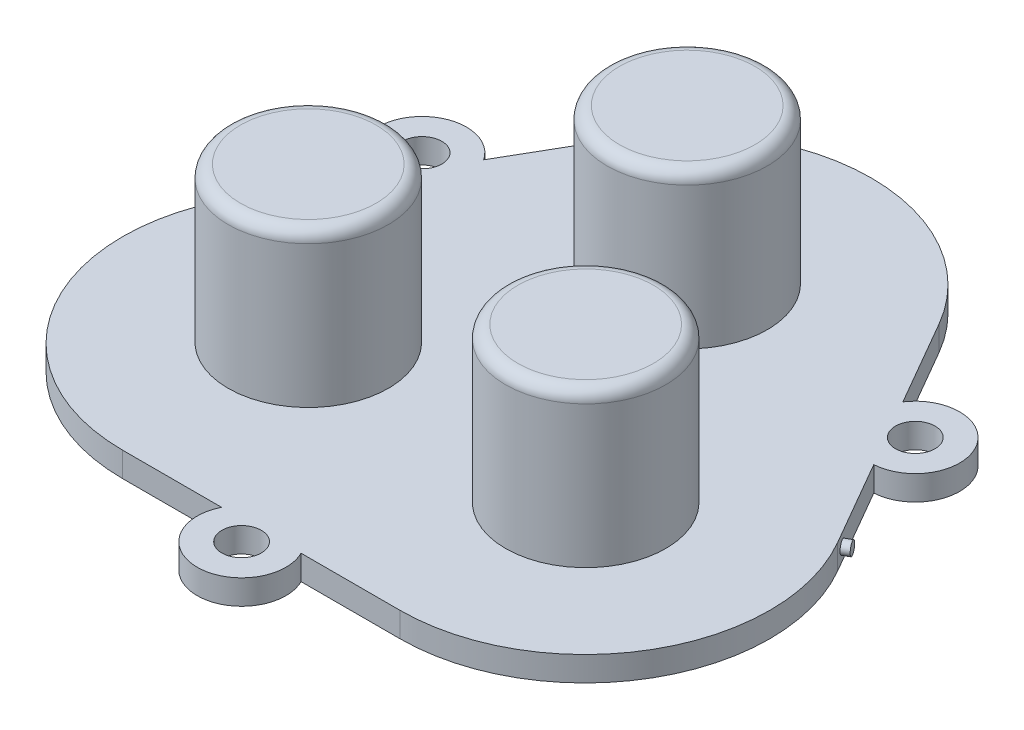
from build123d import *

# Parameters (mm, degrees)
SKETCH5_R           = 1.6
BOSS_EXTRUDE2_DEPTH = 2
SKETCH6_R           = 6.5
BOSS_EXTRUDE3_DEPTH = 14.5
FILLET1_R           = 1
SKETCH7_R           = 0.5
BOSS_EXTRUDE4_DEPTH = 0.6


with BuildPart() as part:
    # Sketch5 → Boss-Extrude2 (new body)
    with BuildSketch(Plane(origin=(0, 0, 0), x_dir=(1, 0, 0), z_dir=(0, 1, 0))):
        with BuildLine():
            Line((-11.250000051, -22.142785594), (-3.22490315, -22.142785594))
            ThreePointArc((-3.22490315, -22.142785594), (-5.1e-08, -27.342785594), (3.224903048, -22.142785594))
            Line((3.224903048, -22.142785594), (11.249999949, -22.142785594))
            ThreePointArc((11.249999949, -22.142785594), (24.240381006, -14.642785594), (24.240381006, 0.357214406))
            Line((24.240381006, 0.357214406), (20.227832555, 7.30715219))
            ThreePointArc((20.227832555, 7.30715219), (23.118713105, 12.700000199), (17.002929456, 12.892848208))
            Line((17.002929456, 12.892848208), (12.990381006, 19.842785992))
            ThreePointArc((12.990381006, 19.842785992), (-5.1e-08, 27.342785992), (-12.990381108, 19.842785992))
            Line((-12.990381108, 19.842785992), (-17.002929558, 12.892848208))
            ThreePointArc((-17.002929558, 12.892848208), (-23.118713208, 12.700000199), (-20.227832658, 7.30715219))
            Line((-20.227832658, 7.30715219), (-24.240381108, 0.357214406))
            ThreePointArc((-24.240381108, 0.357214406), (-24.240381108, -14.642785594), (-11.250000051, -22.142785594))
        make_face()
        with Locations((20.001021652, 10.900000199)):
            Circle(SKETCH5_R, mode=Mode.SUBTRACT)
        with Locations((-5.1e-08, -23.742785594)):
            Circle(SKETCH5_R, mode=Mode.SUBTRACT)
        with Locations((-20.001021754, 10.900000199)):
            Circle(SKETCH5_R, mode=Mode.SUBTRACT)
    extrude(amount=BOSS_EXTRUDE2_DEPTH)

    # Sketch6 → Boss-Extrude3 (add)
    with BuildSketch(Plane(origin=(0, 0, 0), x_dir=(1, 0, 0), z_dir=(0, 1, 0))):
        with Locations((-0.060025126, 12.462836141)):
            Circle(SKETCH6_R)
        with Locations((11.189974874, -7.022735444)):
            Circle(SKETCH6_R)
        with Locations((-11.310025126, -7.022735444)):
            Circle(SKETCH6_R)
    extrude(amount=BOSS_EXTRUDE3_DEPTH)

    # Fillet1
    fillet1_edges = [part.edges().sort_by_distance(p)[0] for p in [
        (-6.560025126, 14.5, -12.462836141),
        (4.689974874, 14.5, 7.022735444),
        (-17.810025126, 14.5, 7.022735444),
    ]]
    fillet(fillet1_edges, radius=FILLET1_R)

    # Sketch7 → Boss-Extrude4 (add)
    with BuildSketch(Plane(origin=(18.334964129, 0, -10.585696476), x_dir=(-0.5, 0, -0.866025404), z_dir=(0.866025404, 0, -0.5))):
        with Locations((-10.763992659, 1)):
            Circle(SKETCH7_R)
    extrude(amount=BOSS_EXTRUDE4_DEPTH)


solid = part.part
